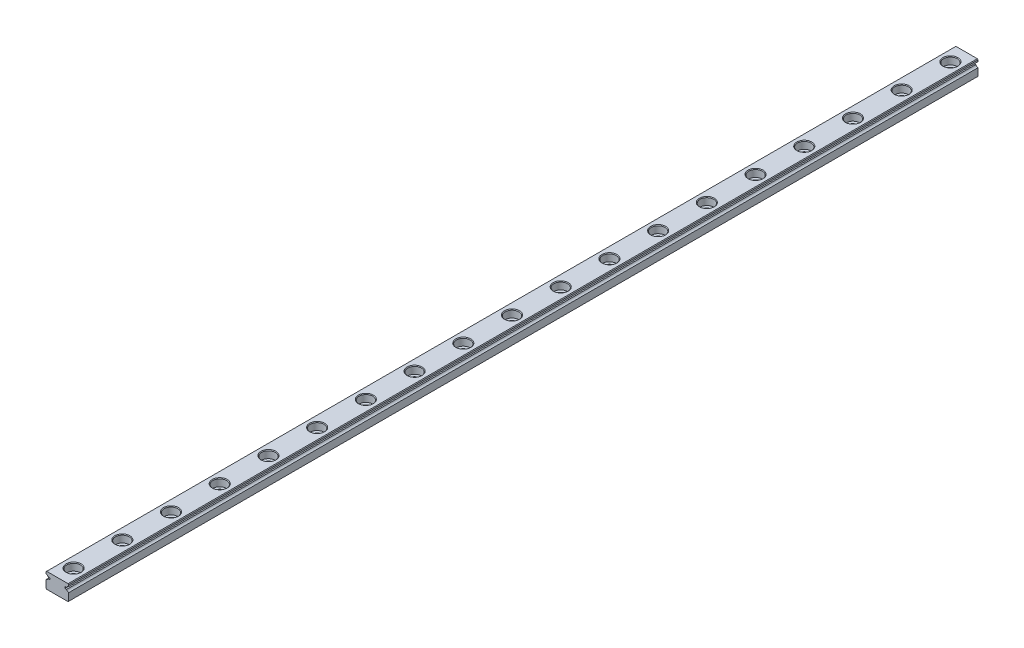
from build123d import *

# Parameters (mm, degrees)
EXTRUDE1_DEPTH             = 280
EXTRUDE2_REACH             = 282.063
SKETCH2_R                  = 1.2
SKETCH_R                   = 2.1
SKETCH_R_2                 = 1.2
EXTRUDE4_DEPTH             = 2.3
CHAMFER1_SIZE              = 0.2
LPATTERN1_COUNT            = 19
LPATTERN1_PITCH            = 15
CHAMFER1_OF_LPATTERN1_SIZE = 0.2


with BuildPart() as part:
    # Sketch1 → Extrude1 (new body)
    with BuildSketch(Plane.XY):
        with BuildLine():
            Line((-3.3, -2.4), (3.3, -2.4))
            Line((3.3, -2.4), (3.5, -2.2))
            Line((3.5, -2.2), (3.5, 0.106274607))
            ThreePointArc((3.5, 0.106274607), (3.091294745, 0.282570681), (2.840065792, 0.65))
            Line((2.840065792, 0.65), (2.340065792, 0.65))
            Line((2.340065792, 0.65), (2.340065792, 1.15))
            Line((2.340065792, 1.15), (2.840065792, 1.15))
            ThreePointArc((2.840065792, 1.15), (3.091294745, 1.517429319), (3.5, 1.693725393))
            Line((3.5, 1.693725393), (3.5, 2.2))
            Line((3.5, 2.2), (3.3, 2.4))
            Line((3.3, 2.4), (-3.3, 2.4))
            Line((-3.3, 2.4), (-3.5, 2.2))
            Line((-3.5, 2.2), (-3.5, 1.693725393))
            ThreePointArc((-3.5, 1.693725393), (-3.091294745, 1.517429319), (-2.840065792, 1.15))
            Line((-2.840065792, 1.15), (-2.340065792, 1.15))
            Line((-2.340065792, 1.15), (-2.340065792, 0.65))
            Line((-2.340065792, 0.65), (-2.840065792, 0.65))
            ThreePointArc((-2.840065792, 0.65), (-3.091294745, 0.282570681), (-3.5, 0.106274607))
            Line((-3.5, 0.106274607), (-3.5, -2.2))
            Line((-3.5, -2.2), (-3.3, -2.4))
        make_face()
    extrude(amount=EXTRUDE1_DEPTH)

    # Sketch2 → Extrude2 (cut, up to next)
    with BuildSketch(Plane(origin=(0, 2.4, 0), x_dir=(1, 0, 0), z_dir=(0, 1, 0)), mode=Mode.PRIVATE) as extrude2_sk1:
        with Locations((0, -5)):
            Circle(SKETCH2_R)
    extrude2_tool1 = extrude(extrude2_sk1.sketch, amount=-EXTRUDE2_REACH, mode=Mode.PRIVATE) & part.part
    extrude2 = extrude2_tool1.solids().sort_by_distance((0, 2.4, 5))[0]
    add(extrude2, mode=Mode.SUBTRACT)

    # Sketch → Extrude4 (cut)
    with BuildSketch(Plane(origin=(0, 2.4, 0), x_dir=(1, 0, 0), z_dir=(0, 1, 0))):
        with Locations((0, -5)):
            Circle(SKETCH_R)
        with Locations((0, -5)):
            Circle(SKETCH_R_2, mode=Mode.SUBTRACT)
    extrude4 = extrude(amount=-EXTRUDE4_DEPTH, mode=Mode.SUBTRACT)

    # Chamfer1
    chamfer1_edges = [part.edges().sort_by_distance(p)[0] for p in [
        (-1.2, -2.4, 5),
        (-2.1, 2.4, 5),
    ]]
    chamfer(chamfer1_edges, length=CHAMFER1_SIZE)

    # LPattern1: Extrude2, Extrude4 ×19
    with Locations(*[(0, 0, i * LPATTERN1_PITCH) for i in range(1, LPATTERN1_COUNT)]):
        add(extrude2, mode=Mode.SUBTRACT)
        add(extrude4, mode=Mode.SUBTRACT)

    # Chamfer1 of LPattern1
    chamfer1_of_lpattern1_edges = [part.edges().sort_by_distance(p)[0] for p in [
        (-1.2, -2.4, 20),
        (-2.1, 2.4, 20),
        (-1.2, -2.4, 35),
        (-2.1, 2.4, 35),
        (-1.2, -2.4, 50),
        (-2.1, 2.4, 50),
        (-1.2, -2.4, 65),
        (-2.1, 2.4, 65),
        (-1.2, -2.4, 80),
        (-2.1, 2.4, 80),
        (-1.2, -2.4, 95),
        (-2.1, 2.4, 95),
        (-1.2, -2.4, 110),
        (-2.1, 2.4, 110),
        (-1.2, -2.4, 125),
        (-2.1, 2.4, 125),
        (-1.2, -2.4, 140),
        (-2.1, 2.4, 140),
        (-1.2, -2.4, 155),
        (-2.1, 2.4, 155),
        (-1.2, -2.4, 170),
        (-2.1, 2.4, 170),
        (-1.2, -2.4, 185),
        (-2.1, 2.4, 185),
        (-1.2, -2.4, 200),
        (-2.1, 2.4, 200),
        (-1.2, -2.4, 215),
        (-2.1, 2.4, 215),
        (-1.2, -2.4, 230),
        (-2.1, 2.4, 230),
        (-1.2, -2.4, 245),
        (-2.1, 2.4, 245),
        (-1.2, -2.4, 260),
        (-2.1, 2.4, 260),
        (-1.2, -2.4, 275),
        (-2.1, 2.4, 275),
    ]]
    chamfer(chamfer1_of_lpattern1_edges, length=CHAMFER1_OF_LPATTERN1_SIZE)


solid = part.part
